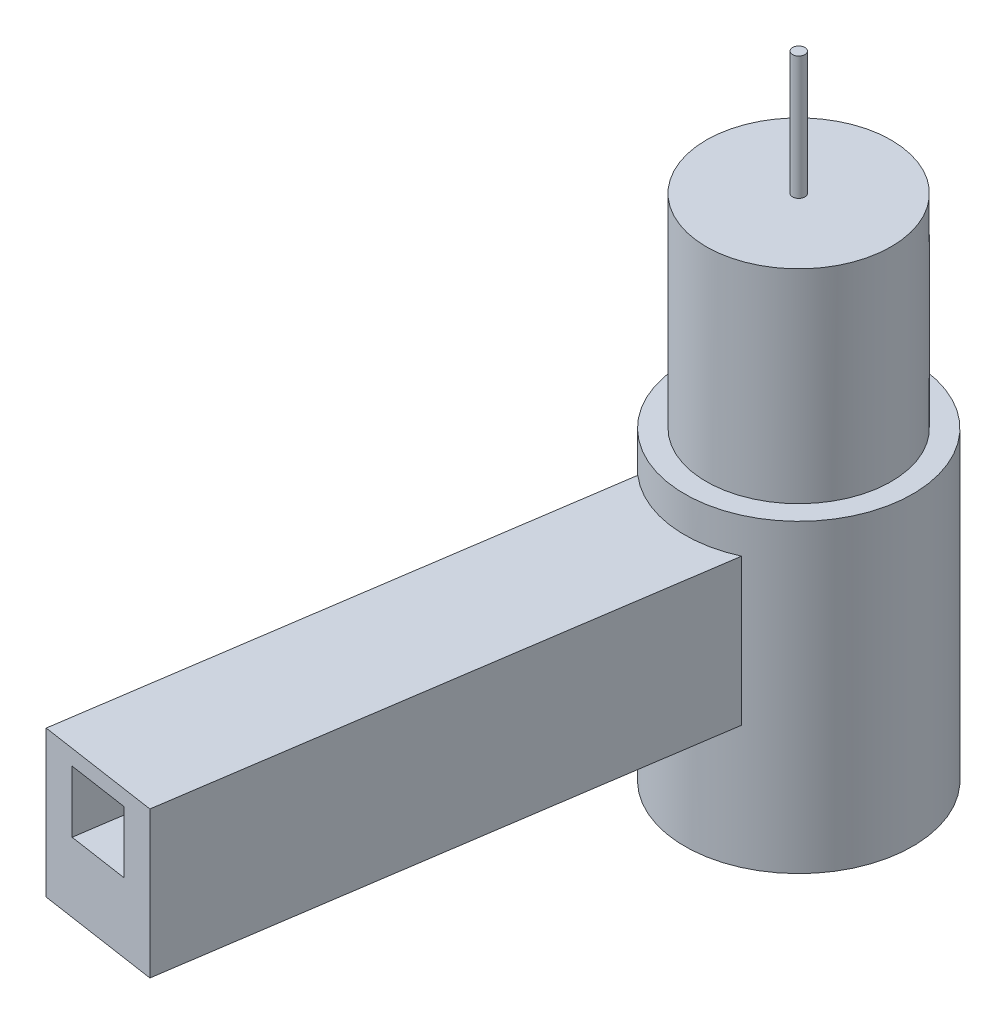
from build123d import *

# Parameters (mm, degrees)
SKETCH1_R           = 3
BOSS_EXTRUDE1_DEPTH = 16.5
SKETCH2_R           = 3.7
BOSS_EXTRUDE2_DEPTH = 9.9
BOSS_EXTRUDE3_START = -8.75
BOSS_EXTRUDE3_DEPTH = 4.75
SKETCH4_R           = 0.2
BOSS_EXTRUDE4_DEPTH = 4
SKETCH5_W           = 2
SKETCH5_H           = 2
CUT_EXTRUDE1_DEPTH  = 20


with BuildPart() as part:
    # Sketch1 → Boss-Extrude1 (new body)
    with BuildSketch(Plane(origin=(0, 0, 0), x_dir=(1, 0, 0), z_dir=(0, 1, 0))):
        Circle(SKETCH1_R)
    extrude(amount=BOSS_EXTRUDE1_DEPTH)

    # Sketch2 → Boss-Extrude2 (add)
    with BuildSketch(Plane.XZ):
        Circle(SKETCH2_R)
    extrude(amount=-BOSS_EXTRUDE2_DEPTH)

    # Sketch3 → Boss-Extrude3 (add)
    with BuildSketch(Plane.XZ.offset(BOSS_EXTRUDE3_START)):
        with BuildLine():
            Line((-2.438116725, 2.783089441), (-4.934027826, 19.484747096))
            Line((-4.934027826, 19.484747096), (-0.977958543, 20.075945733))
            Line((-0.977958543, 20.075945733), (1.517952558, 3.374288078))
            ThreePointArc((1.517952558, 3.374288078), (-0.546858739, 3.659364087), (-2.438116725, 2.783089441))
        make_face()
    extrude(amount=BOSS_EXTRUDE3_DEPTH)

    # Sketch4 → Boss-Extrude4 (add)
    with BuildSketch(Plane(origin=(0, 16.5, 0), x_dir=(1, 0, 0), z_dir=(0, 1, 0))):
        Circle(SKETCH4_R)
    extrude(amount=BOSS_EXTRUDE4_DEPTH)

    # Sketch5 → Cut-Extrude1 (cut)
    with BuildSketch(Plane(origin=(-2.955993184, 0, 19.780346415), x_dir=(0.989017321, 0, 0.147799659), z_dir=(-0.147799659, 0, 0.989017321))):
        with Locations((0, 7.25)):
            Rectangle(SKETCH5_W, SKETCH5_H)
    extrude(amount=-CUT_EXTRUDE1_DEPTH, mode=Mode.SUBTRACT)


solid = part.part
